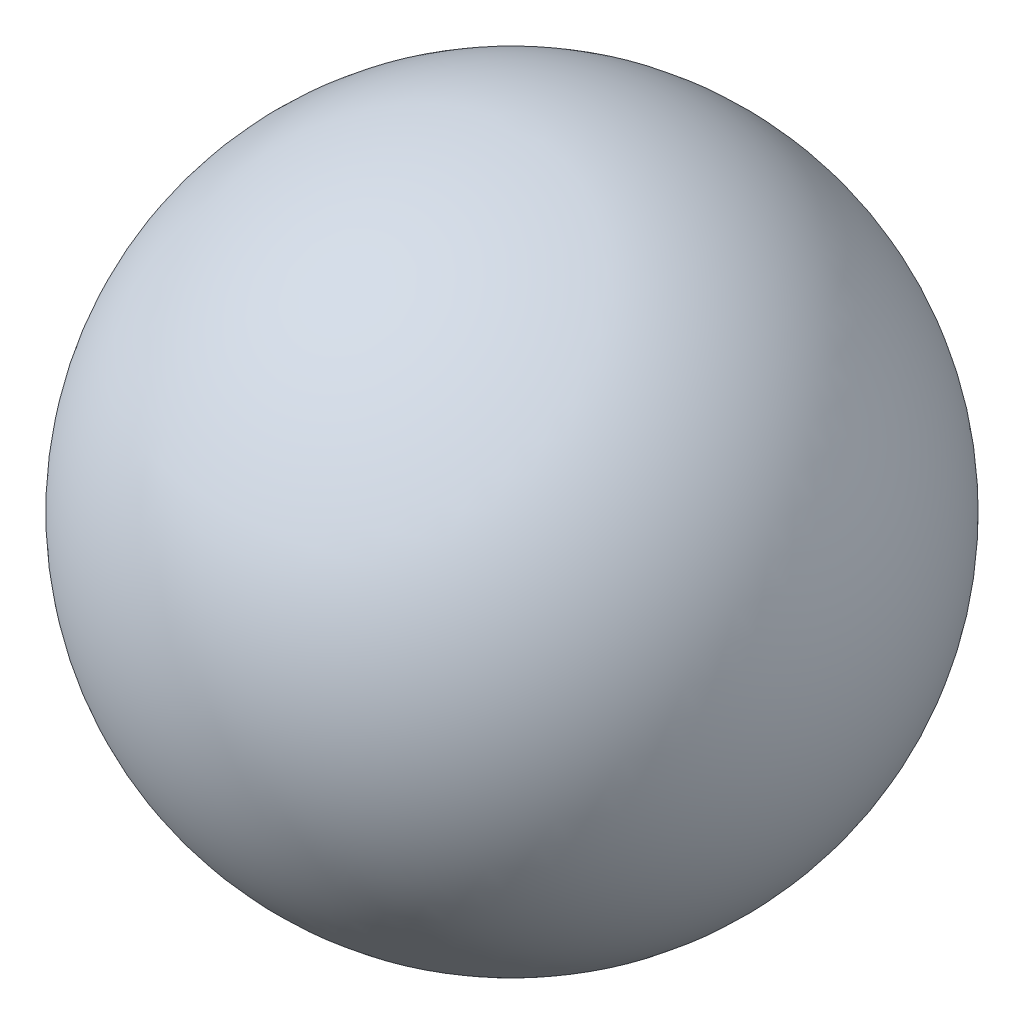
from build123d import *


with BuildPart() as part:
    # Sketch3 → Revolve1 (revolve)
    with BuildSketch(Plane.XY):
        with BuildLine():
            Line((0, 0), (0, 19.05))
            ThreePointArc((0, 19.05), (9.525, 9.525), (0, 0))
        make_face()
    revolve(axis=Axis((0, 0, 0), (0, 1, 0)))


solid = part.part
